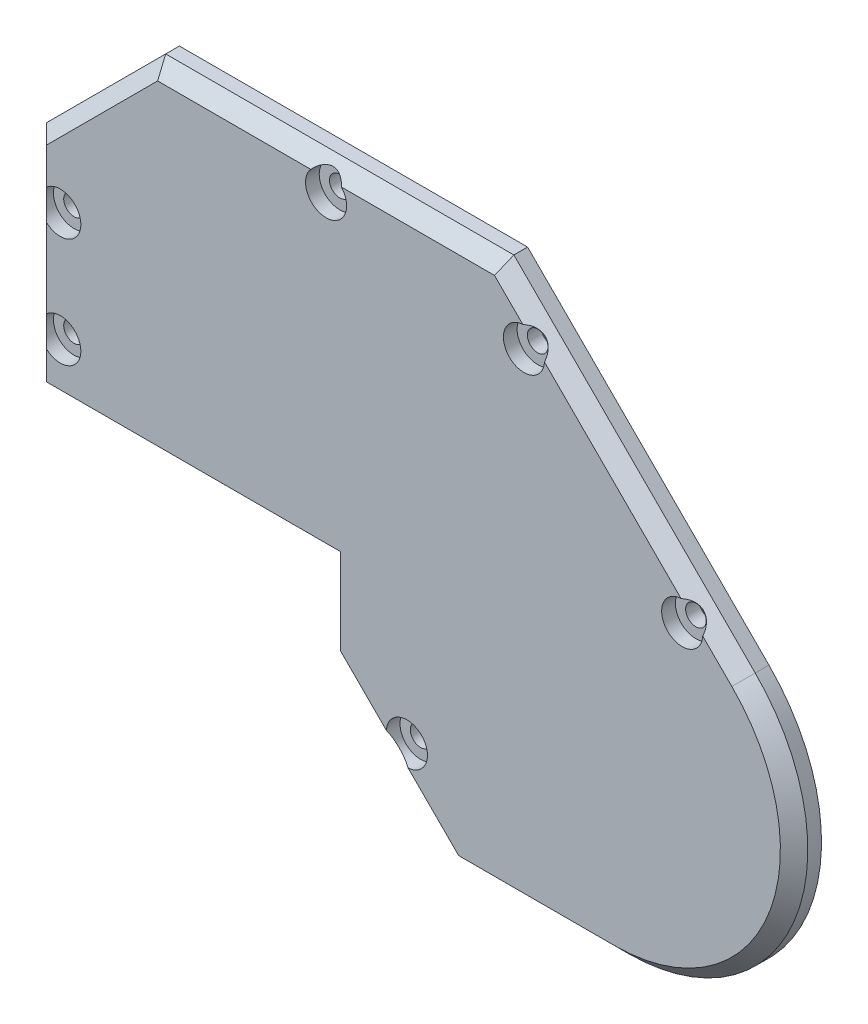
from build123d import *

# Parameters (mm, degrees)
RESSALTO_EXTRUS_O1_DEPTH = 48
ESBO_O12_R               = 1.5
CORTE_EXTRUS_O10_DEPTH   = 10
ESBO_O13_R               = 1.5
CORTE_EXTRUS_O11_DEPTH   = 10
ESBO_O14_R               = 1.5
CORTE_EXTRUS_O12_DEPTH   = 10
ESBO_O15_R               = 1.5
CORTE_EXTRUS_O13_DEPTH   = 10
CORTE_EXTRUS_O14_DEPTH   = 10
ESBO_O17_R               = 4
ESBO_O17_W               = 2.8
ESBO_O17_H               = 2.8
RESSALTO_EXTRUS_O2_DEPTH = 4
ESBO_O18_R               = 1.5
RESSALTO_EXTRUS_O3_DEPTH = 4
CHANFRO1_SIZE            = 2
CORTE_EXTRUS_O15_DEPTH   = 48
ESBO_O20_R               = 3
CORTE_EXTRUS_O16_DEPTH   = 2
CORTE_EXTRUS_O17_DEPTH   = 10


with BuildPart() as part:
    # Model → Ressalto-extrusão1 (new body)
    with BuildSketch(Plane.XY):
        with BuildLine():
            Line((-0.7, 0), (39, 0))
            Line((39, 0), (39.7, 0))
            Line((39.7, 0), (39.7, -11.380317396))
            Line((39.7, -11.380317396), (50.182424304, -21.8627417))
            Line((50.182424304, -21.8627417), (58.119682605, -29.8))
            Line((58.119682605, -29.8), (81.7, -29.8))
            ThreePointArc((81.7, -29.8), (105.905643752, -13.626305928), (100.226197667, 14.926197667))
            Line((100.226197667, 14.926197667), (65.00338056, 50.149014774))
            Line((65.00338056, 50.149014774), (50.111140335, 50.149014774))
            Line((50.111140335, 50.149014774), (14.181595121, 50.149014774))
            Line((14.181595121, 50.149014774), (-3.2, 32.767419653))
            Line((-3.2, 32.767419653), (-3.2, 5))
            Line((-3.2, 5), (-3.2, 0))
            Line((-3.2, 0), (-0.7, 0))
        make_face()
        with BuildLine():
            Line((-0.7, 2.5), (39, 2.5))
            Line((39, 2.5), (39.7, 2.5))
            Line((39.7, 2.5), (42.2, 2.5))
            Line((42.2, 2.5), (42.2, -10.34478349))
            Line((42.2, -10.34478349), (51.950191257, -20.094974747))
            Line((51.950191257, -20.094974747), (59.15521651, -27.3))
            Line((59.15521651, -27.3), (81.7, -27.3))
            ThreePointArc((81.7, -27.3), (103.595944921, -12.669597347), (98.458430714, 13.158430714))
            Line((98.458430714, 13.158430714), (63.967846654, 47.649014774))
            Line((63.967846654, 47.649014774), (50.111140335, 47.649014774))
            Line((50.111140335, 47.649014774), (15.217129027, 47.649014774))
            Line((15.217129027, 47.649014774), (-0.7, 31.731885747))
            Line((-0.7, 31.731885747), (-0.7, 2.5))
        make_face(mode=Mode.SUBTRACT)
    extrude(amount=RESSALTO_EXTRUS_O1_DEPTH)

    # Esboço12 → Corte-extrusão10 (cut)
    with BuildSketch(Plane(origin=(57.576197667, 57.576197667, 0), x_dir=(0, 0, -1), z_dir=(0.707106781, 0.707106781, 0))):
        with Locations((-44, -19.409915607)):
            Circle(ESBO_O12_R)
        with Locations((-44, -51.409915607)):
            Circle(ESBO_O12_R)
    extrude(amount=-CORTE_EXTRUS_O10_DEPTH, mode=Mode.SUBTRACT)

    # Esboço13 → Corte-extrusão11 (cut)
    with BuildSketch(Plane(origin=(0, 50.149014774, 0), x_dir=(1, 0, 0), z_dir=(0, 1, 0))):
        with Locations((39.59248784, -44)):
            Circle(ESBO_O13_R)
    extrude(amount=-CORTE_EXTRUS_O11_DEPTH, mode=Mode.SUBTRACT)

    # Esboço14 → Corte-extrusão12 (cut)
    with BuildSketch(Plane.ZY.offset(3.2)):
        with Locations((44, 24.383709827)):
            Circle(ESBO_O14_R)
        with Locations((44, 8.383709827)):
            Circle(ESBO_O14_R)
    extrude(amount=-CORTE_EXTRUS_O12_DEPTH, mode=Mode.SUBTRACT)

    # Esboço15 → Corte-extrusão13 (cut)
    with BuildSketch(Plane(origin=(14.159841302, 14.159841302, 0), x_dir=(0, 0, 1), z_dir=(-0.707106781, -0.707106781, 0))):
        with Locations((44, -48.648946546)):
            Circle(ESBO_O15_R)
    extrude(amount=-CORTE_EXTRUS_O13_DEPTH, mode=Mode.SUBTRACT)

    # Esboço16 → Corte-extrusão14 (cut)
    with BuildSketch(Plane.XY.offset(48)):
        Polygon((39.7, 0), (39.7, -2), (42.2, -2), (42.2, 2.5), (-0.7, 2.5), (-0.7, 0), align=None)
    extrude(amount=-CORTE_EXTRUS_O14_DEPTH, mode=Mode.SUBTRACT)

    # Esboço17 → Ressalto-extrusão2 (add)
    with BuildSketch(Plane(origin=(0, 0, 0), x_dir=(-1, 0, 0), z_dir=(0, 0, -1))):
        with Locations((-91.100070488, 18.395470597)):
            Circle(ESBO_O17_R)
        with Locations((-91.100070488, 18.395470597)):
            Rectangle(ESBO_O17_W, ESBO_O17_H, mode=Mode.SUBTRACT)
        with Locations((-68.47265349, 41.022887595)):
            Circle(ESBO_O17_R)
        with Locations((-68.47265349, 41.022887595)):
            Rectangle(ESBO_O17_W, ESBO_O17_H, mode=Mode.SUBTRACT)
        with Locations((-39.59248784, 46.149014774)):
            Circle(ESBO_O17_R)
        with Locations((-39.59248784, 46.149014774)):
            Rectangle(ESBO_O17_W, ESBO_O17_H, mode=Mode.SUBTRACT)
        with Locations((-0.8, 24.383709827)):
            Circle(ESBO_O17_R)
        with Locations((-0.8, 24.383709827)):
            Rectangle(ESBO_O17_W, ESBO_O17_H, mode=Mode.SUBTRACT)
        with Locations((-0.8, 8.383709827)):
            Circle(ESBO_O17_R)
        with Locations((-0.8, 8.383709827)):
            Rectangle(ESBO_O17_W, ESBO_O17_H, mode=Mode.SUBTRACT)
        with Locations((-51.388268427, -17.411731573)):
            Circle(ESBO_O17_R)
        with Locations((-51.388268427, -17.411731573)):
            Rectangle(ESBO_O17_W, ESBO_O17_H, mode=Mode.SUBTRACT)
    extrude(amount=-RESSALTO_EXTRUS_O2_DEPTH)

    # Esboço18 → Ressalto-extrusão3 (add)
    with BuildSketch(Plane(origin=(0, 0, 0), x_dir=(-1, 0, 0), z_dir=(0, 0, -1))):
        with BuildLine():
            Line((-65.00338056, 50.149014774), (-14.181595121, 50.149014774))
            Line((-14.181595121, 50.149014774), (3.2, 32.767419653))
            Line((3.2, 32.767419653), (3.2, 0))
            Line((3.2, 0), (-39.7, 0))
            Line((-39.7, 0), (-39.7, -11.380317396))
            Line((-39.7, -11.380317396), (-58.119682605, -29.8))
            Line((-58.119682605, -29.8), (-81.7, -29.8))
            ThreePointArc((-81.7, -29.8), (-105.905643752, -13.626305928), (-100.226197667, 14.926197667))
            Line((-100.226197667, 14.926197667), (-65.00338056, 50.149014774))
        make_face()
        with Locations((-91.568699638, 17.926841447)):
            Circle(ESBO_O18_R, mode=Mode.SUBTRACT)
        with Locations((-68.47265349, 41.022887595)):
            Circle(ESBO_O18_R, mode=Mode.SUBTRACT)
        with Locations((-39.59248784, 46.149014774)):
            Circle(ESBO_O18_R, mode=Mode.SUBTRACT)
        with Locations((-0.8, 24.383709827)):
            Circle(ESBO_O18_R, mode=Mode.SUBTRACT)
        with Locations((-51.388268427, -17.411731573)):
            Circle(ESBO_O18_R, mode=Mode.SUBTRACT)
        with Locations((-0.8, 8.383709827)):
            Circle(ESBO_O18_R, mode=Mode.SUBTRACT)
    extrude(amount=RESSALTO_EXTRUS_O3_DEPTH)

    # Chanfro1
    chanfro1_edges = [part.edges().sort_by_distance(p)[0] for p in [
        (82.614789114, 32.53760622, -4),
        (105.905643752, -13.626305928, -4),
        (69.909841302, -29.8, -4),
        (48.909841302, -20.590158698, -4),
        (39.7, -5.690158698, -4),
        (18.25, 0, -4),
        (-3.2, 16.383709827, -4),
        (5.49079756, 41.458217213, -4),
        (39.59248784, 50.149014774, -4),
    ]]
    chamfer(chanfro1_edges, length=CHANFRO1_SIZE)

    # Esboço19 → Corte-extrusão15 (cut)
    with BuildSketch(Plane.XY.offset(48)):
        with BuildLine():
            Line((65.00338056, 50.149014774), (14.181595121, 50.149014774))
            Line((14.181595121, 50.149014774), (-3.2, 32.767419653))
            Line((-3.2, 32.767419653), (-3.2, 0))
            Line((-3.2, 0), (39.7, 0))
            Line((39.7, 0), (39.7, -11.380317396))
            Line((39.7, -11.380317396), (58.119682605, -29.8))
            Line((58.119682605, -29.8), (81.7, -29.8))
            ThreePointArc((81.7, -29.8), (105.905643752, -13.626305928), (100.226197667, 14.926197667))
            Line((100.226197667, 14.926197667), (65.00338056, 50.149014774))
        make_face()
    extrude(amount=-CORTE_EXTRUS_O15_DEPTH, mode=Mode.SUBTRACT)

    # Esboço20 → Corte-extrusão16 (cut)
    with BuildSketch(Plane(origin=(0, 0, -4), x_dir=(-1, 0, 0), z_dir=(0, 0, -1))):
        with Locations((-0.8, 24.383709827)):
            Circle(ESBO_O20_R)
        with Locations((-0.8, 8.383709827)):
            Circle(ESBO_O20_R)
        with Locations((-39.59248784, 46.149014774)):
            Circle(ESBO_O20_R)
        with Locations((-68.47265349, 41.022887595)):
            Circle(ESBO_O20_R)
        with Locations((-51.388268427, -17.411731573)):
            Circle(ESBO_O20_R)
        with Locations((-91.568699638, 17.926841447)):
            Circle(ESBO_O20_R)
    extrude(amount=-CORTE_EXTRUS_O16_DEPTH, mode=Mode.SUBTRACT)


with BuildPart() as body_2:
    # Espelhar1: mirrored copy
    add(part.part.mirror(Plane(origin=(81.7, -3.6, 0), x_dir=(1, 0, 0), z_dir=(0, 0, -1))))


with BuildPart() as part_1:
    add(part.part)

    # Esboço21 → Corte-extrusão17 (cut)
    with BuildSketch(Plane.XY):
        with BuildLine():
            Line((100.226197667, 14.926197667), (65.00338056, 50.149014774))
            Line((65.00338056, 50.149014774), (14.181595121, 50.149014774))
            Line((14.181595121, 50.149014774), (-3.2, 32.767419653))
            Line((-3.2, 32.767419653), (-3.2, 0))
            Line((-3.2, 0), (39.7, 0))
            Line((39.7, 0), (39.7, -11.380317396))
            Line((39.7, -11.380317396), (58.119682605, -29.8))
            Line((58.119682605, -29.8), (81.7, -29.8))
            ThreePointArc((81.7, -29.8), (105.905643752, -13.626305928), (100.226197667, 14.926197667))
        make_face()
    extrude(amount=-CORTE_EXTRUS_O17_DEPTH, mode=Mode.SUBTRACT)


solid = body_2.part
